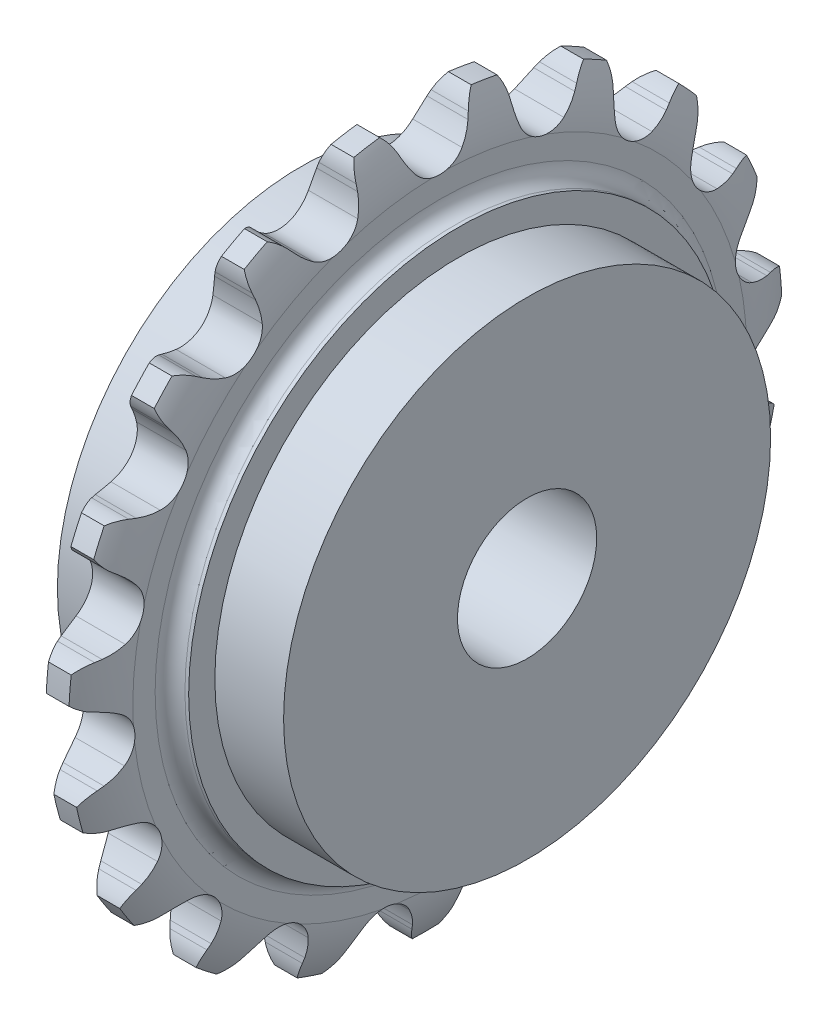
from build123d import *

# Parameters (mm, degrees)
EXTRUDECUTONE_DEPTH     = 2.548609941
PATTERNONE_COUNT        = 19
SKETCHHOLE_R            = 13.995
CUT_EXTRUDEA_DEPTH      = 3.548609941
CUT_EXTRUDEA_DEPTH_BACK = 3.548609941
EXTRUDE_START           = -2.54861
SKETCH_1_R              = 13.995
SKETCH_1_R_2            = 4
EXTRUDE_1_DEPTH         = 6.5


with BuildPart() as part:
    # Sketch1 → Revolve 2 (revolve)
    with BuildSketch(Plane.XY):
        with BuildLine():
            Line((-2.548609941, 0), (-2.548609941, 15.5))
            Line((-2.548609941, 15.5), (-2.334627953, 15.5))
            ThreePointArc((-2.334627953, 15.5), (-1.729395493, 15.750695493), (-1.4787, 16.355927953))
            Line((-1.4787, 16.355927953), (-1.4787, 17.639819882))
            ThreePointArc((-1.4787, 17.639819882), (-1.235926901, 19.118968366), (-0.6532, 20.5))
            Line((-0.6532, 20.5), (0.6532, 20.5))
            ThreePointArc((0.6532, 20.5), (1.235926901, 19.118968366), (1.4787, 17.639819882))
            Line((1.4787, 17.639819882), (1.4787, 16.355927953))
            ThreePointArc((1.4787, 16.355927953), (1.729395493, 15.750695493), (2.334627953, 15.5))
            Line((2.334627953, 15.5), (2.548609941, 15.5))
            Line((2.548609941, 15.5), (2.548609941, 0))
            Line((2.548609941, 0), (-2.548609941, 0))
        make_face()
    revolve(axis=Axis((-4, 0, 0), (1, 0, 0)))

    # Sketch2 → ExtrudeCutOne (cut, symmetric)
    with BuildSketch(Plane(origin=(0, 0, 0), x_dir=(0, 0, -1), z_dir=(1, 0, 0))):
        with BuildLine():
            Line((1.923595704, 19.214545724), (2.051302736, 19.513874475))
            ThreePointArc((2.051302736, 19.513874475), (2.29677678, 19.953128273), (2.629441127, 20.33066746))
            ThreePointArc((2.629441127, 20.33066746), (0, 20.5), (-2.629441127, 20.33066746))
            ThreePointArc((-2.629441127, 20.33066746), (-2.29677678, 19.953128273), (-2.051302736, 19.513874475))
            Line((-2.051302736, 19.513874475), (-1.923595704, 19.214545724))
            ThreePointArc((-1.923595704, 19.214545724), (-1.665639605, 18.705391161), (-1.343215995, 18.234410552))
            ThreePointArc((-1.343215995, 18.234410552), (0, 17.581569882), (1.343215995, 18.234410552))
            ThreePointArc((1.343215995, 18.234410552), (1.665639605, 18.705391161), (1.923595704, 19.214545724))
        make_face()
    extrudecutone = extrude(amount=EXTRUDECUTONE_DEPTH, both=True, mode=Mode.SUBTRACT)

    # PatternOne: ExtrudeCutOne ×19 about axis
    patternone_axis = Axis((0, 0, 0), (1, 0, 0))
    for i in range(1, PATTERNONE_COUNT):
        add(extrudecutone.rotate(patternone_axis, i * 360 / PATTERNONE_COUNT), mode=Mode.SUBTRACT)

    # SketchHole → Cut-ExtrudeA (cut, two sides)
    with BuildSketch(Plane(origin=(0, 0, 0), x_dir=(0, 0, -1), z_dir=(1, 0, 0))) as cut_extrudea_sk:
        Circle(SKETCHHOLE_R)
    extrude(amount=CUT_EXTRUDEA_DEPTH, mode=Mode.SUBTRACT)
    extrude(cut_extrudea_sk.sketch, amount=-CUT_EXTRUDEA_DEPTH_BACK, mode=Mode.SUBTRACT)

    # 草图1 → 凸台-拉伸1 (add, symmetric)
    with BuildSketch(Plane.ZY.offset(2.548609941).offset(EXTRUDE_START)):
        Circle(SKETCH_1_R)
        Circle(SKETCH_1_R_2, mode=Mode.SUBTRACT)
    extrude(amount=EXTRUDE_1_DEPTH, both=True)


solid = part.part
